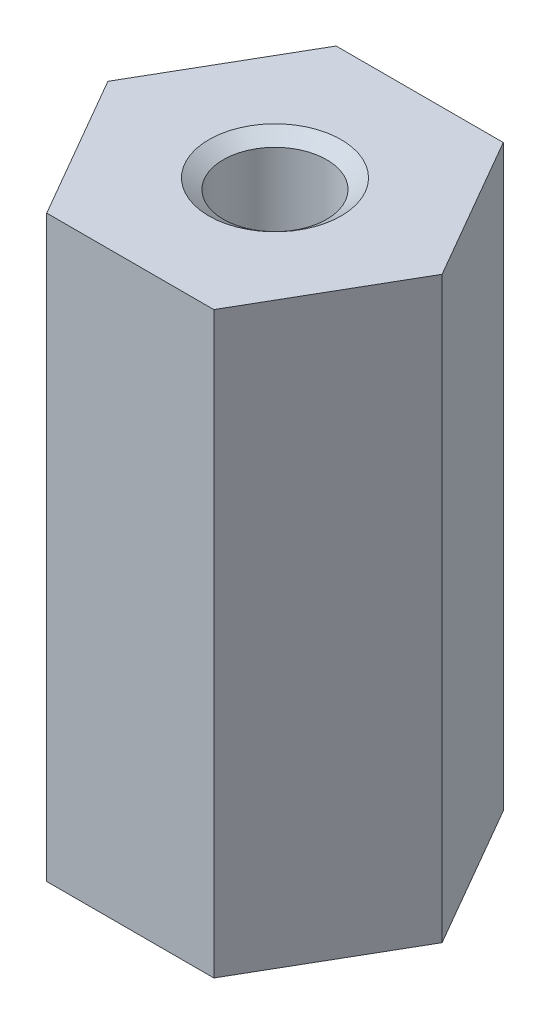
from build123d import *

# Parameters (mm, degrees)
EXTRUDE_1_DEPTH = 14


with BuildPart() as part:
    # Эскиз1 → Бобышка-Вытянуть1 (new body)
    with BuildSketch(Plane(origin=(0, 0, 0), x_dir=(1, 0, 0), z_dir=(0, 1, 0))):
        Polygon((4.041451884, 0), (2.020725942, 3.5), (-2.020725942, 3.5), (-4.041451884, 0), (-2.020725942, -3.5), (2.020725942, -3.5), align=None)
    extrude(amount=EXTRUDE_1_DEPTH)

    # Эскиз2 → Отверстие обработанное метчиком M3x0.51 (revolve, cut)
    with BuildSketch(Plane(origin=(0, 14, 0), x_dir=(0, 0, 1), z_dir=(1, 0, 0))):
        Polygon((0, 0), (0, 14), (1.6, 14), (1.25, 13.754927362), (1.25, 0.245072638), (1.6, 0), align=None)
    revolve(axis=Axis((0, 20.35, 0), (0, -1, 0)), mode=Mode.SUBTRACT)


solid = part.part
